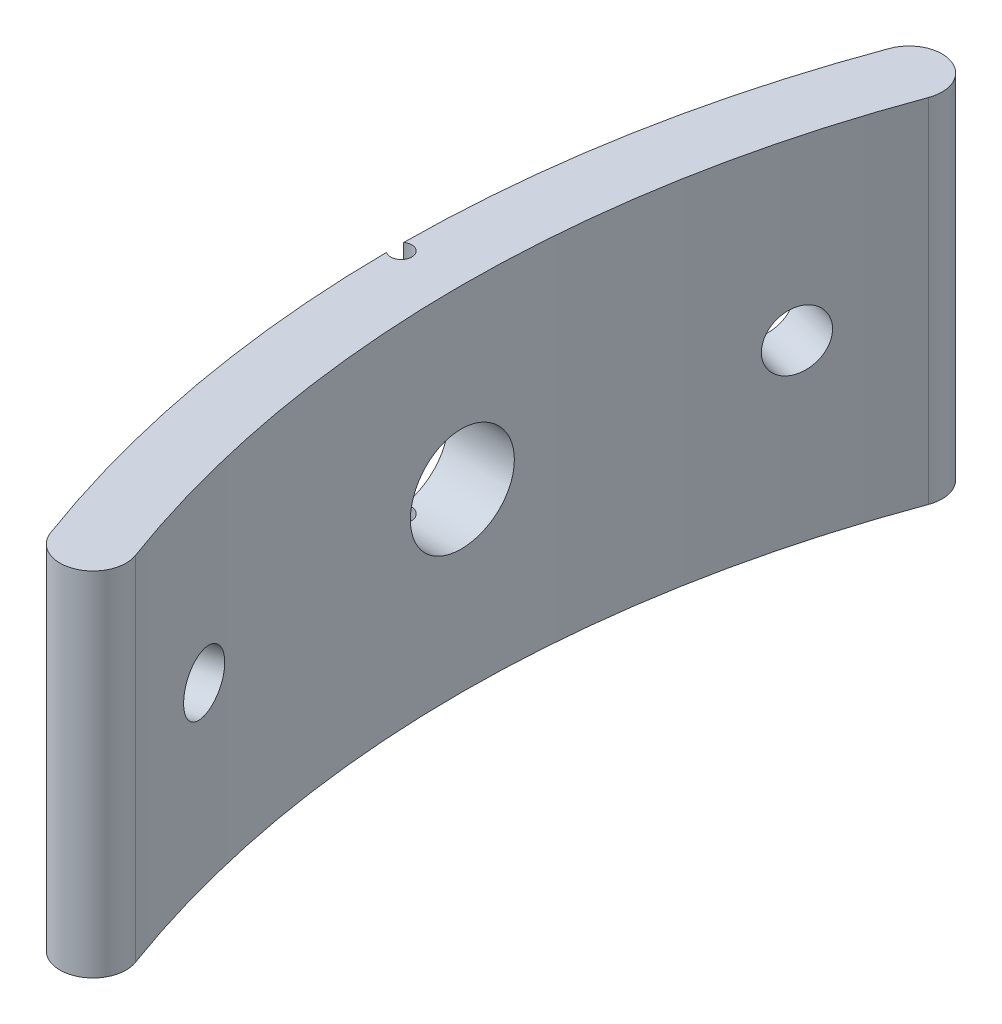
from build123d import *

# Parameters (mm, degrees)
BOSS_EXTRUDE2_DEPTH = 10
SKETCH9_R           = 1.65
CUT_EXTRUDE3_DEPTH  = 10
SKETCH10_R          = 2.95
CUT_EXTRUDE4_DEPTH  = 74.842839982
SKETCH12_R          = 3
CUT_EXTRUDE5_DEPTH  = 2
SKETCH13_R          = 0.6
CUT_EXTRUDE6_DEPTH  = 76.846984244


with BuildPart() as part:
    # Sketch3 → Boss-Extrude2 (new, symmetric)
    with BuildSketch(Plane(origin=(0, 0, 0), x_dir=(1, 0, 0), z_dir=(0, 1, 0))):
        with BuildLine():
            ThreePointArc((-60.981554588, 22.5), (-65, 0), (-60.981554588, -22.5))
            ThreePointArc((-60.981554588, -22.5), (-62.091599432, -24.908121767), (-64.499721199, -23.798076923))
            ThreePointArc((-64.499721199, -23.798076923), (-68.75, 0), (-64.499721199, 23.798076923))
            ThreePointArc((-64.499721199, 23.798076923), (-62.091599432, 24.908121767), (-60.981554588, 22.5))
        make_face()
    extrude(amount=BOSS_EXTRUDE2_DEPTH, both=True)

    # Sketch9 → Cut-Extrude3 (cut, symmetric)
    with BuildSketch(Plane(origin=(-62.785178709, 0, -16.823237932), x_dir=(0, -1, 0), z_dir=(0.9659258262890673, 0, 0.25881904510252474))):
        Circle(SKETCH9_R)
    cut_extrude3 = extrude(amount=CUT_EXTRUDE3_DEPTH, both=True, mode=Mode.SUBTRACT)

    # Mirror1: Cut-Extrude3 across plane
    add(cut_extrude3.mirror(Plane.XY), mode=Mode.SUBTRACT)

    # Sketch10 → Cut-Extrude4 (cut, through all)
    with BuildSketch(Plane(origin=(0, 0, 0), x_dir=(0, 0, -1), z_dir=(1, 0, 0))):
        Circle(SKETCH10_R)
    extrude(amount=-CUT_EXTRUDE4_DEPTH, mode=Mode.SUBTRACT)

    # Sketch12 → Cut-Extrude5 (cut)
    with BuildSketch(Plane(origin=(-67.61480784, 0, -18.117333157), x_dir=(0, -1, 0), z_dir=(0.9659258262890673, 0, 0.25881904510252474))):
        Circle(SKETCH12_R)
    cut_extrude5 = extrude(amount=CUT_EXTRUDE5_DEPTH, mode=Mode.SUBTRACT)

    # Mirror2: Cut-Extrude5 across plane
    add(cut_extrude5.mirror(Plane.XY), mode=Mode.SUBTRACT)

    # Sketch13 → Cut-Extrude6 (cut, through all)
    with BuildSketch(Plane(origin=(0, 10, 0), x_dir=(1, 0, 0), z_dir=(0, 1, 0))):
        with Locations((-68.4, 0)):
            Circle(SKETCH13_R)
    extrude(amount=-CUT_EXTRUDE6_DEPTH, mode=Mode.SUBTRACT)


solid = part.part
